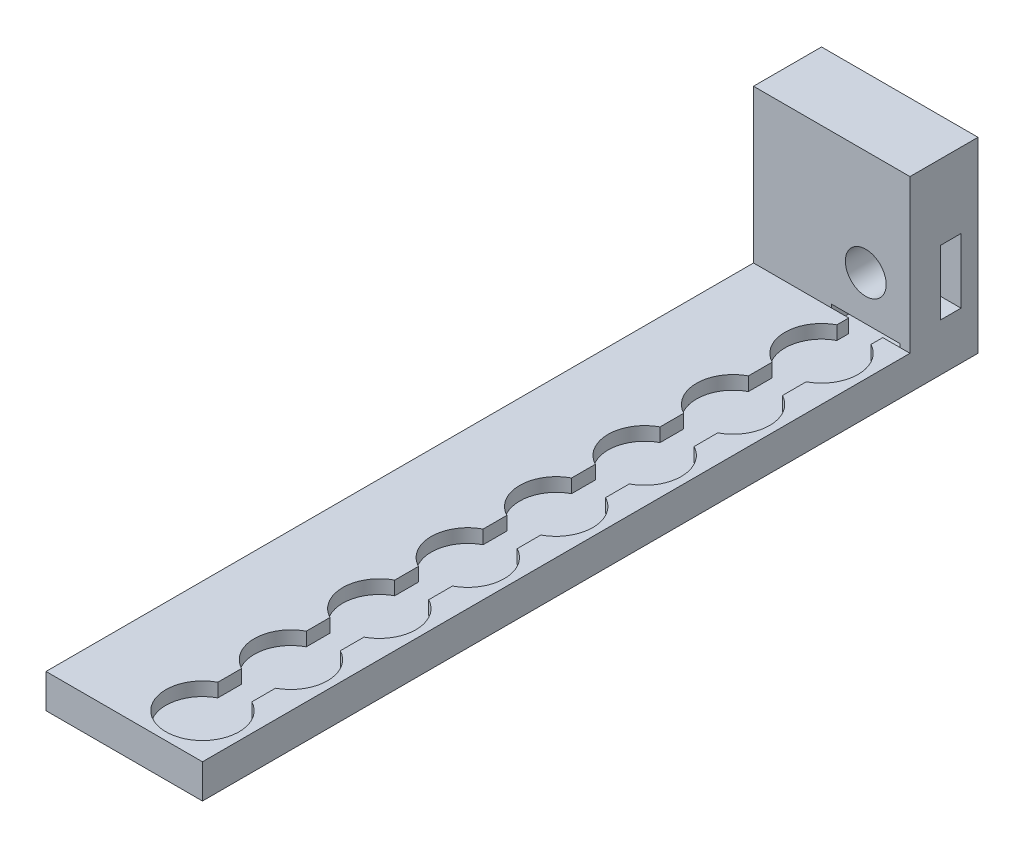
from build123d import *

# Parameters (mm, degrees)
SKETCH5_W           = 26
SKETCH5_H           = 26
BOSS_EXTRUDE1_DEPTH = 10
SKETCH4_R           = 10.75
CUT_EXTRUDE1_DEPTH  = 4
SKETCH6_W           = 10
SKETCH6_H           = 3.483566845
CUT_EXTRUDE2_DEPTH  = 4
LPATTERN1_COUNT     = 8
LPATTERN1_PITCH     = 26
SKETCH7_W           = 10
SKETCH7_H           = 4
CUT_EXTRUDE3_DEPTH  = 183
SKETCH8_W           = 208
SKETCH8_H           = 10
BOSS_EXTRUDE2_DEPTH = 20
SKETCH9_W           = 46
SKETCH9_H           = 10
BOSS_EXTRUDE3_DEPTH = 20
SKETCH10_W          = 46
SKETCH10_H          = 20
BOSS_EXTRUDE4_DEPTH = 45
SKETCH13_W          = 20
SKETCH13_H          = 5
CUT_EXTRUDE4_DEPTH  = 20
SKETCH14_R          = 6
CUT_EXTRUDE5_DEPTH  = 45
SKETCH15_W          = 6
SKETCH15_H          = 19
CUT_EXTRUDE6_DEPTH  = 20


with BuildPart() as part:
    # Sketch5 → Boss-Extrude1 (new body)
    with BuildSketch(Plane(origin=(0, 0, 0), x_dir=(1, 0, 0), z_dir=(0, 1, 0))):
        Rectangle(SKETCH5_W, SKETCH5_H)
    boss_extrude1 = extrude(amount=-BOSS_EXTRUDE1_DEPTH)

    # Sketch4 → Cut-Extrude1 (cut)
    with BuildSketch(Plane(origin=(0, 0, 0), x_dir=(1, 0, 0), z_dir=(0, 1, 0))):
        Circle(SKETCH4_R)
    cut_extrude1 = extrude(amount=-CUT_EXTRUDE1_DEPTH, mode=Mode.SUBTRACT)

    # Sketch6 → Cut-Extrude2 (cut)
    with BuildSketch(Plane(origin=(0, 0, 0), x_dir=(1, 0, 0), z_dir=(0, 1, 0))):
        with Locations((0, 11.258216578)):
            Rectangle(SKETCH6_W, SKETCH6_H)
    cut_extrude2 = extrude(amount=-CUT_EXTRUDE2_DEPTH, mode=Mode.SUBTRACT)

    # LPattern1: Boss-Extrude1, Cut-Extrude1, Cut-Extrude2 ×8
    with Locations(*[(0, 0, -i * LPATTERN1_PITCH) for i in range(1, LPATTERN1_COUNT)]):
        add(boss_extrude1)
        add(cut_extrude1, mode=Mode.SUBTRACT)
        add(cut_extrude2, mode=Mode.SUBTRACT)

    # Sketch7 → Cut-Extrude3 (cut, through all)
    with BuildSketch(Plane.XY.offset(-13)):
        with Locations((0, -2)):
            Rectangle(SKETCH7_W, SKETCH7_H)
    extrude(amount=-CUT_EXTRUDE3_DEPTH, mode=Mode.SUBTRACT)

    # Sketch8 → Boss-Extrude2 (add)
    with BuildSketch(Plane.ZY.offset(13)):
        with Locations((-91, -5)):
            Rectangle(SKETCH8_W, SKETCH8_H)
    extrude(amount=BOSS_EXTRUDE2_DEPTH)

    # Sketch9 → Boss-Extrude3 (add)
    with BuildSketch(Plane(origin=(0, 0, -195), x_dir=(-1, 0, 0), z_dir=(0, 0, -1))):
        with Locations((10, -5)):
            Rectangle(SKETCH9_W, SKETCH9_H)
    extrude(amount=BOSS_EXTRUDE3_DEPTH)

    # Sketch10 → Boss-Extrude4 (add)
    with BuildSketch(Plane(origin=(0, 0, 0), x_dir=(1, 0, 0), z_dir=(0, 1, 0))):
        with Locations((-10, 205)):
            Rectangle(SKETCH10_W, SKETCH10_H)
    extrude(amount=BOSS_EXTRUDE4_DEPTH)

    # Sketch13 → Cut-Extrude4 (cut)
    with BuildSketch(Plane(origin=(0, 0, -215), x_dir=(-1, 0, 0), z_dir=(0, 0, -1))):
        with Locations((0, -1.5)):
            Rectangle(SKETCH13_W, SKETCH13_H)
    extrude(amount=-CUT_EXTRUDE4_DEPTH, mode=Mode.SUBTRACT)

    # Sketch14 → Cut-Extrude5 (cut)
    with BuildSketch(Plane(origin=(0, 0, -215), x_dir=(-1, 0, 0), z_dir=(0, 0, -1))):
        with Locations((0, 14)):
            Circle(SKETCH14_R)
    extrude(amount=-CUT_EXTRUDE5_DEPTH, mode=Mode.SUBTRACT)

    # Sketch15 → Cut-Extrude6 (cut)
    with BuildSketch(Plane(origin=(13, 0, 0), x_dir=(0, 0, -1), z_dir=(1, 0, 0))):
        with Locations((207, 13.5)):
            Rectangle(SKETCH15_W, SKETCH15_H)
    extrude(amount=-CUT_EXTRUDE6_DEPTH, mode=Mode.SUBTRACT)


solid = part.part
